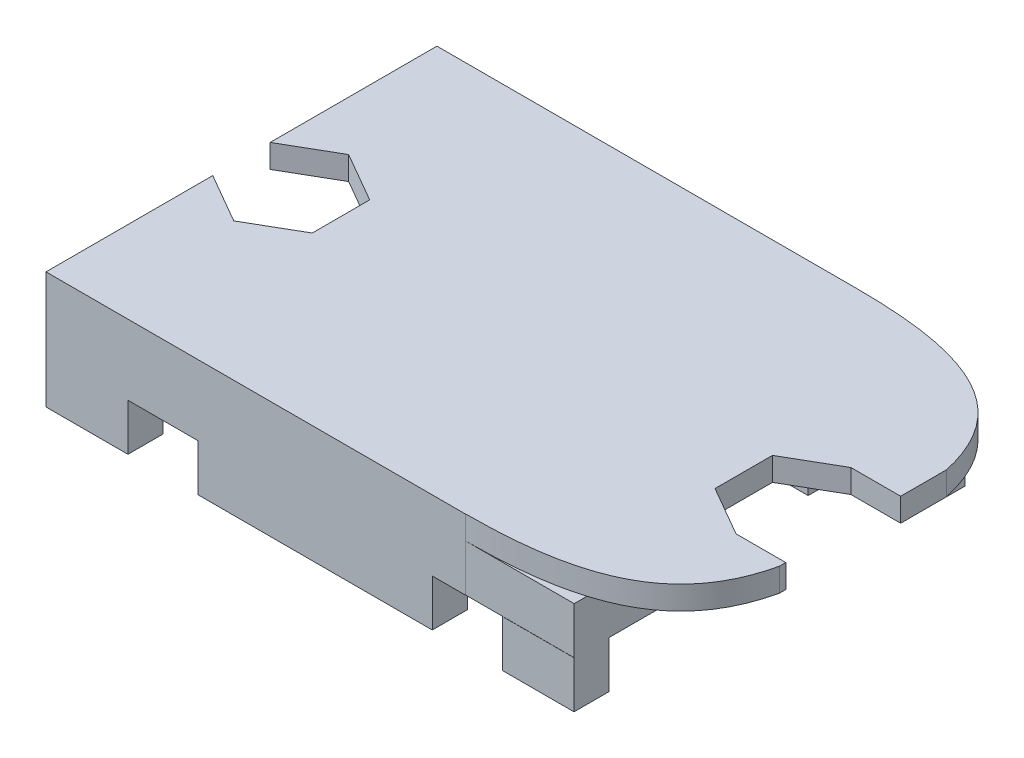
from build123d import *

# Parameters (mm, degrees)
SKETCH1_W           = 22.5552
SKETCH1_H           = 12.7
BOSS_EXTRUDE1_DEPTH = 1
SKETCH2_W           = 5
SKETCH2_H           = 7.3
CUT_EXTRUDE1_DEPTH  = 1
SKETCH3_W           = 5
SKETCH3_H           = 5
CUT_EXTRUDE2_DEPTH  = 1
BOSS_EXTRUDE2_DEPTH = 1
SKETCH5_W           = 26.5552
SKETCH5_H           = 16.7
BOSS_EXTRUDE3_DEPTH = 1
CUT_EXTRUDE3_DEPTH  = 1
CUT_EXTRUDE4_DEPTH  = 1
CUT_EXTRUDE5_START  = -4
CUT_EXTRUDE5_DEPTH  = 5
SKETCH10_W          = 22.5552
SKETCH10_H          = 2
BOSS_EXTRUDE4_DEPTH = 2
SKETCH11_W          = 8.919893548
SKETCH11_H          = 0.730490532
CUT_EXTRUDE6_DEPTH  = 3
SKETCH12_W          = 22.5552
SKETCH12_H          = 1.5
BOSS_EXTRUDE5_DEPTH = 2
SKETCH13_W          = 3
SKETCH13_H          = 1.5
CUT_EXTRUDE7_DEPTH  = 2
SKETCH14_W          = 2.125
SKETCH14_H          = 1.226869322
CUT_EXTRUDE8_DEPTH  = 1


with BuildPart() as part:
    # Sketch1 → Boss-Extrude1 (new body)
    with BuildSketch(Plane(origin=(0, 0, 0), x_dir=(1, 0, 0), z_dir=(0, 1, 0))):
        with Locations((-28.763088774, 14.606547542)):
            Rectangle(SKETCH1_W, SKETCH1_H)
    extrude(amount=BOSS_EXTRUDE1_DEPTH)

    # Sketch2 → Cut-Extrude1 (cut)
    with BuildSketch(Plane(origin=(0, 1, 0), x_dir=(1, 0, 0), z_dir=(0, 1, 0))):
        with Locations((-37.540688774, 14.606547542)):
            Rectangle(SKETCH2_W, SKETCH2_H)
    extrude(amount=-CUT_EXTRUDE1_DEPTH, mode=Mode.SUBTRACT)

    # Sketch3 → Cut-Extrude2 (cut)
    with BuildSketch(Plane(origin=(0, 1, 0), x_dir=(1, 0, 0), z_dir=(0, 1, 0))):
        with Locations((-19.985488774, 13.756547542)):
            Rectangle(SKETCH3_W, SKETCH3_H)
    extrude(amount=-CUT_EXTRUDE2_DEPTH, mode=Mode.SUBTRACT)

    # Sketch4 → Boss-Extrude2 (add)
    with BuildSketch(Plane.XZ):
        Polygon((-40.040688774, -8.256547542), (-40.040688774, -8.756547542), (-17.985488774, -8.756547542), (-17.985488774, -10.256547542), (-17.485488774, -10.256547542), (-17.485488774, -8.256547542), align=None)
        Polygon((-17.985488774, -20.456547542), (-40.040688774, -20.456547542), (-40.040688774, -20.956547542), (-17.485488774, -20.956547542), (-17.485488774, -18.456547542), (-17.985488774, -18.456547542), align=None)
    extrude(amount=BOSS_EXTRUDE2_DEPTH)

    # Sketch5 → Boss-Extrude3 (add)
    with BuildSketch(Plane(origin=(0, 1, 0), x_dir=(1, 0, 0), z_dir=(0, 1, 0))):
        with Locations((-26.763088774, 14.606547542)):
            Rectangle(SKETCH5_W, SKETCH5_H)
    extrude(amount=BOSS_EXTRUDE3_DEPTH)

    # Sketch6 → Cut-Extrude3 (cut)
    with BuildSketch(Plane(origin=(0, 2, 0), x_dir=(1, 0, 0), z_dir=(0, 1, 0))):
        Polygon((-40.040688774, 13.37967822), (-37.915688774, 12.152808898), (-35.790688774, 13.37967822), (-35.790688774, 15.833416864), (-37.915688774, 17.060286186), (-40.040688774, 15.833416864), align=None)
    extrude(amount=-CUT_EXTRUDE3_DEPTH, mode=Mode.SUBTRACT)

    # Sketch7 → Cut-Extrude4 (cut)
    with BuildSketch(Plane(origin=(0, 1, 0), x_dir=(-1, 0, 0), z_dir=(0, -1, 0))):
        Polygon((17.735488774, 14.983416864), (15.610488774, 16.210286186), (13.485488774, 14.983416864), (13.485488774, 12.52967822), (15.610488774, 11.302808898), (17.735488774, 12.52967822), align=None)
    extrude(amount=-CUT_EXTRUDE4_DEPTH, mode=Mode.SUBTRACT)

    # Sketch8 → Cut-Extrude5 (cut)
    with BuildSketch(Plane(origin=(0, 2, 0), x_dir=(1, 0, 0), z_dir=(0, 1, 0)).offset(CUT_EXTRUDE5_START)):
        with BuildLine():
            Line((-13.485488774, 22.956547542), (-22.127760886, 22.956547542))
            add(Edge.make_bspline(
                [(-22.127760886, 22.956547542), (-17.367981555, 22.956547542), (-14.30272025, 21.87197064), (-13.485488774, 18.176213027)],
                knots=[0, 0, 0, 0, 1, 1, 1, 1], degree=3))
            Line((-13.485488774, 18.176213027), (-13.485488774, 22.956547542))
        make_face()
    cut_extrude5 = extrude(amount=CUT_EXTRUDE5_DEPTH, mode=Mode.SUBTRACT)

    # Mirror2: Cut-Extrude5 across plane
    add(cut_extrude5.mirror(Plane.XY.offset(-14.61)), mode=Mode.SUBTRACT)

    # Sketch10 → Boss-Extrude4 (add)
    with BuildSketch(Plane(origin=(0, 1, 0), x_dir=(-1, 0, 0), z_dir=(0, -1, 0))):
        with Locations((28.763088774, 7.256547542)):
            Rectangle(SKETCH10_W, SKETCH10_H)
        with Locations((28.763088774, 21.956547542)):
            Rectangle(SKETCH10_W, SKETCH10_H)
    extrude(amount=BOSS_EXTRUDE4_DEPTH)

    # Sketch11 → Cut-Extrude6 (cut)
    with BuildSketch(Plane(origin=(0, 2, 0), x_dir=(1, 0, 0), z_dir=(0, 1, 0))):
        with Locations((-17.667814112, 5.898207192)):
            Rectangle(SKETCH11_W, SKETCH11_H)
    extrude(amount=-CUT_EXTRUDE6_DEPTH, mode=Mode.SUBTRACT)

    # Sketch12 → Boss-Extrude5 (add)
    with BuildSketch(Plane(origin=(0, -1, 0), x_dir=(-1, 0, 0), z_dir=(0, -1, 0))):
        with Locations((28.763088774, 7.006547542)):
            Rectangle(SKETCH12_W, SKETCH12_H)
        with Locations((28.763088774, 22.206547542)):
            Rectangle(SKETCH12_W, SKETCH12_H)
    extrude(amount=BOSS_EXTRUDE5_DEPTH)

    # Sketch13 → Cut-Extrude7 (cut)
    with BuildSketch(Plane(origin=(0, -3, 0), x_dir=(-1, 0, 0), z_dir=(0, -1, 0))):
        with Locations((35.040688774, 7.006547542)):
            Rectangle(SKETCH13_W, SKETCH13_H)
        with Locations((35.040688774, 22.206547542)):
            Rectangle(SKETCH13_W, SKETCH13_H)
        with Locations((22.040688774, 7.006547542)):
            Rectangle(SKETCH13_W, SKETCH13_H)
        with Locations((22.040688774, 22.206547542)):
            Rectangle(SKETCH13_W, SKETCH13_H)
    extrude(amount=-CUT_EXTRUDE7_DEPTH, mode=Mode.SUBTRACT)

    # Sketch14 → Cut-Extrude8 (cut)
    with BuildSketch(Plane(origin=(0, 2, 0), x_dir=(1, 0, 0), z_dir=(0, 1, 0))):
        with Locations((-14.547988774, 15.596851525)):
            Rectangle(SKETCH14_W, SKETCH14_H)
        with Locations((-14.547988774, 11.916243559)):
            Rectangle(SKETCH14_W, SKETCH14_H)
    extrude(amount=-CUT_EXTRUDE8_DEPTH, mode=Mode.SUBTRACT)


solid = part.part
